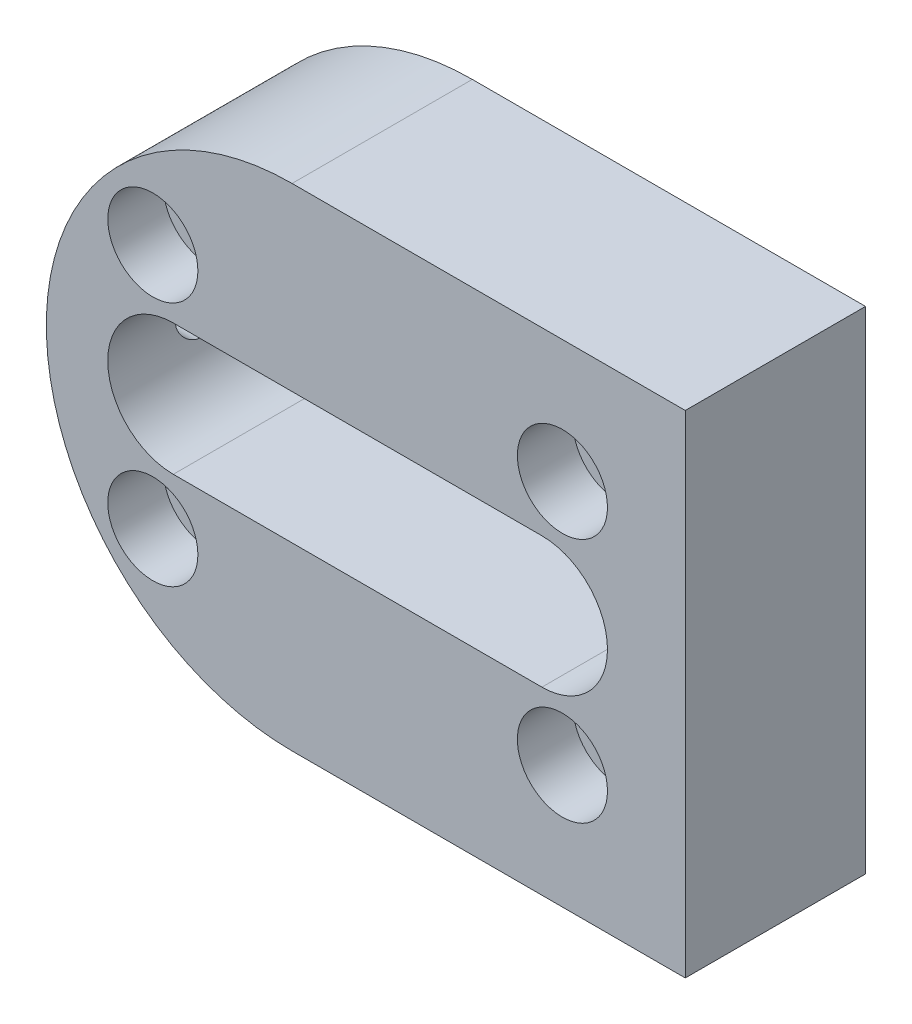
from build123d import *

# Parameters (mm, degrees)
EXTRUDE_1_DEPTH           = 22
HOLE_WIZARD_1_D           = 6.6
HOLE_WIZARD_1_CBORE_D     = 11
HOLE_WIZARD_1_CBORE_DEPTH = 6.8
MM_1_REACH                = 86.291
MM_1_BORE_R               = 2.75


with BuildPart() as part:
    # 草图1 → 凸台-拉伸1 (new body)
    with BuildSketch(Plane.XY):
        with BuildLine():
            Line((-8, 30), (40, 30))
            Line((40, 30), (40, -30))
            Line((40, -30), (-8, -30))
            ThreePointArc((-8, -30), (-38, 0), (-8, 30))
        make_face()
        with BuildLine():
            Line((-22.5, 8), (22.5, 8))
            ThreePointArc((22.5, 8), (30.5, 0), (22.5, -8))
            Line((22.5, -8), (-22.5, -8))
            ThreePointArc((-22.5, -8), (-30.5, 0), (-22.5, 8))
        make_face(mode=Mode.SUBTRACT)
    extrude(amount=EXTRUDE_1_DEPTH)

    # 打孔尺寸(%根据)内六角圆柱头螺钉的类型1 (through all)
    with Locations(Plane(origin=(-25, 15, 22), x_dir=(1, 0, 0), z_dir=(0, 0, 1))):
        with Locations((0, 0), (0, -30), (50, 0), (50, -30)):
            CounterBoreHole(HOLE_WIZARD_1_D / 2, HOLE_WIZARD_1_CBORE_D / 2, HOLE_WIZARD_1_CBORE_DEPTH)

    # 大小mm 暗销孔1 bore (on position points) → 大小mm 暗销孔1 (cut, up to next)
    with BuildSketch(Plane(origin=(-38, 0, 11), x_dir=(0, 0, -1), z_dir=(-1, 0, 0)), mode=Mode.PRIVATE) as mm_1_sk1:
        Circle(MM_1_BORE_R)
    mm_1_tool1 = extrude(mm_1_sk1.sketch, amount=-MM_1_REACH, mode=Mode.PRIVATE) & part.part
    add(mm_1_tool1.solids().sort_by_distance((-38, 0, 11))[0], mode=Mode.SUBTRACT)


solid = part.part
